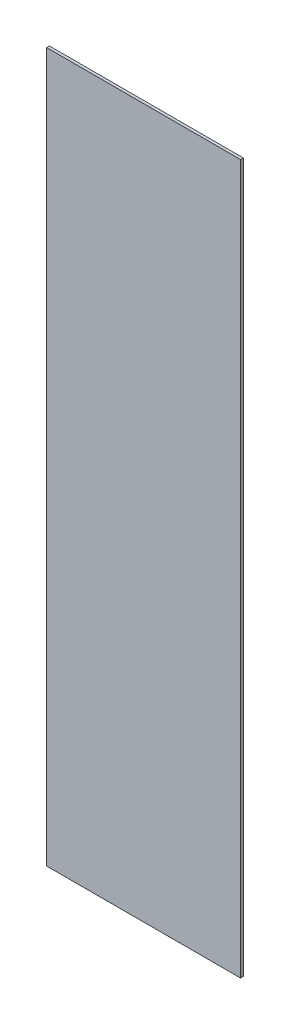
from build123d import *

# Parameters (mm, degrees)
SKETCH1_W           = 177.8
SKETCH1_H           = 650.24
BOSS_EXTRUDE1_DEPTH = 2.54


with BuildPart() as part:
    # Sketch1 → Boss-Extrude1 (new body)
    with BuildSketch(Plane.XY):
        with Locations((-7.428368028, -97.536)):
            Rectangle(SKETCH1_W, SKETCH1_H)
    extrude(amount=BOSS_EXTRUDE1_DEPTH)


solid = part.part
